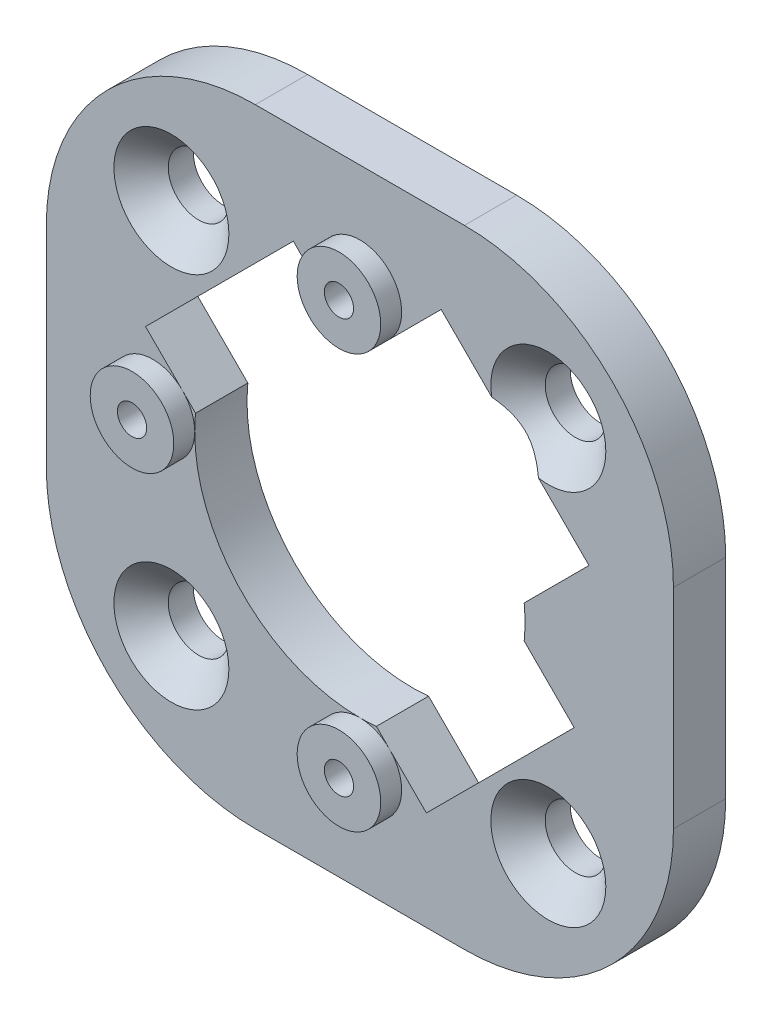
from build123d import *

# Parameters (mm, degrees)
SKETCH1_W                                      = 30
SKETCH1_H                                      = 30
BOSS_EXTRUDE1_DEPTH                            = 2.5
CUT_EXTRUDE1_DEPTH                             = 3.5
SKETCH3_W                                      = 2
SKETCH3_H                                      = 1
SKETCH4_W                                      = 2
SKETCH4_H                                      = 1
SKETCH5_W                                      = 2
SKETCH5_H                                      = 1
CSK_FOR_M2_5_FLAT_HEAD_MACHINE_SCREW1_AT_COUNT = 2
CSK_FOR_M2_5_FLAT_HEAD_MACHINE_SCREW1_AT_PITCH = 18.03122292
CSK_FOR_M2_5_FLAT_HEAD_MACHINE_SCREW_2_COUNT   = 2
CSK_FOR_M2_5_FLAT_HEAD_MACHINE_SCREW_2_PITCH   = 25.5
CSK_FOR_M2_5_FLAT_HEAD_MACHINE_SCREW_3_COUNT   = 2
CSK_FOR_M2_5_FLAT_HEAD_MACHINE_SCREW_3_PITCH   = 18.03122292
F_1_4_1_4_DIAMETER_HOLE1_D                     = 1.4
F_1_4_1_4_DIAMETER_HOLE1_DEPTH                 = 3.5
FILLET1_R                                      = 10


with BuildPart() as part:
    # Sketch1 → Boss-Extrude1 (new body)
    with BuildSketch(Plane(origin=(0, 0, 0), x_dir=(-1, 0, 0), z_dir=(0, 0, -1))):
        Rectangle(SKETCH1_W, SKETCH1_H)
    extrude(amount=-BOSS_EXTRUDE1_DEPTH)

    # Sketch2 → Cut-Extrude1 (cut, through all)
    with BuildSketch(Plane.XY.offset(2.5)):
        with BuildLine():
            Line((-3.181980515, 10.253048327), (-10.253048327, 3.181980515))
            Line((-10.253048327, 3.181980515), (-7.860000362, 0.78893255))
            ThreePointArc((-7.860000362, 0.78893255), (-5.585786438, -5.585786438), (0.78893255, -7.860000362))
            Line((0.78893255, -7.860000362), (3.181980515, -10.253048327))
            Line((3.181980515, -10.253048327), (10.253048327, -3.181980515))
            Line((10.253048327, -3.181980515), (7.860000362, -0.78893255))
            ThreePointArc((7.860000362, -0.78893255), (7.899494937, 0), (7.860000362, 0.78893255))
            Line((7.860000362, 0.78893255), (10.960155108, 3.889087297))
            Line((10.960155108, 3.889087297), (3.889087297, 10.960155108))
            Line((3.889087297, 10.960155108), (0.78893255, 7.860000362))
            ThreePointArc((0.78893255, 7.860000362), (0, 7.899494937), (-0.78893255, 7.860000362))
            Line((-0.78893255, 7.860000362), (-3.181980515, 10.253048327))
        make_face()
    extrude(amount=-CUT_EXTRUDE1_DEPTH, mode=Mode.SUBTRACT)

    # Sketch3 → Revolve1 (revolve)
    with BuildSketch(Plane.XZ):
        with Locations((-8.899494937, 3)):
            Rectangle(SKETCH3_W, SKETCH3_H)
    revolve(axis=Axis((-9.899494937, 0, 3.5), (0, 0, -1)))

    # Sketch4 → Revolve2 (revolve)
    with BuildSketch(Plane.XZ.offset(-9.899494937)):
        with Locations((1, 3)):
            Rectangle(SKETCH4_W, SKETCH4_H)
    revolve(axis=Axis((0, 9.899494937, 3.5), (0, 0, -1)))

    # Sketch5 → Revolve3 (revolve)
    with BuildSketch(Plane.XZ.offset(9.899494937)):
        with Locations((1, 3)):
            Rectangle(SKETCH5_W, SKETCH5_H)
    revolve(axis=Axis((0, -9.899494937, 3.5), (0, 0, -1)))

    # Sketch6 → CSK for M2.5 Flat Head Machine Screw1 (revolve, cut)
    with BuildSketch(Plane(origin=(9.01561146, 9.01561146, 2.5), x_dir=(0, -1, 0), z_dir=(1, 0, 0))):
        Polygon((0, 0), (0, 2.5), (1.45, 2.5), (1.45, 1.3), (2.75, 0), align=None)
    csk_for_m2_5_flat_head_machine_screw1 = revolve(axis=Axis((9.01561146, 9.01561146, 8.85), (0, 0, -1)), mode=Mode.SUBTRACT)

    # CSK for M2.5 Flat Head Machine Screw1 at: CSK for M2.5 Flat Head Machine Screw1 ×2
    with Locations(*[(-i * CSK_FOR_M2_5_FLAT_HEAD_MACHINE_SCREW1_AT_PITCH, 0, 0) for i in range(1, CSK_FOR_M2_5_FLAT_HEAD_MACHINE_SCREW1_AT_COUNT)]):
        add(csk_for_m2_5_flat_head_machine_screw1, mode=Mode.SUBTRACT)

    # CSK for M2.5 Flat Head Machine Screw 2: CSK for M2.5 Flat Head Machine Screw1 ×2
    with Locations(*[Vector(-0.707106781, -0.707106781, 0) * (i * CSK_FOR_M2_5_FLAT_HEAD_MACHINE_SCREW_2_PITCH) for i in range(1, CSK_FOR_M2_5_FLAT_HEAD_MACHINE_SCREW_2_COUNT)]):
        add(csk_for_m2_5_flat_head_machine_screw1, mode=Mode.SUBTRACT)

    # CSK for M2.5 Flat Head Machine Screw 3: CSK for M2.5 Flat Head Machine Screw1 ×2
    with Locations(*[(0, -i * CSK_FOR_M2_5_FLAT_HEAD_MACHINE_SCREW_3_PITCH, 0) for i in range(1, CSK_FOR_M2_5_FLAT_HEAD_MACHINE_SCREW_3_COUNT)]):
        add(csk_for_m2_5_flat_head_machine_screw1, mode=Mode.SUBTRACT)

    # Ø1.4 (1.4) Diameter Hole1
    with Locations(Plane(origin=(0, 0, 0), x_dir=(-1, 0, 0), z_dir=(0, 0, -1))):
        with Locations((9.899494937, 0), (0, -9.899494937), (0, 9.899494937)):
            Hole(F_1_4_1_4_DIAMETER_HOLE1_D / 2, depth=F_1_4_1_4_DIAMETER_HOLE1_DEPTH)

    # Fillet1
    fillet1_edges = [part.edges().sort_by_distance(p)[0] for p in [
        (15, -15, 1.25),
        (15, 15, 1.25),
        (-15, 15, 1.25),
        (-15, -15, 1.25),
    ]]
    fillet(fillet1_edges, radius=FILLET1_R)


solid = part.part
